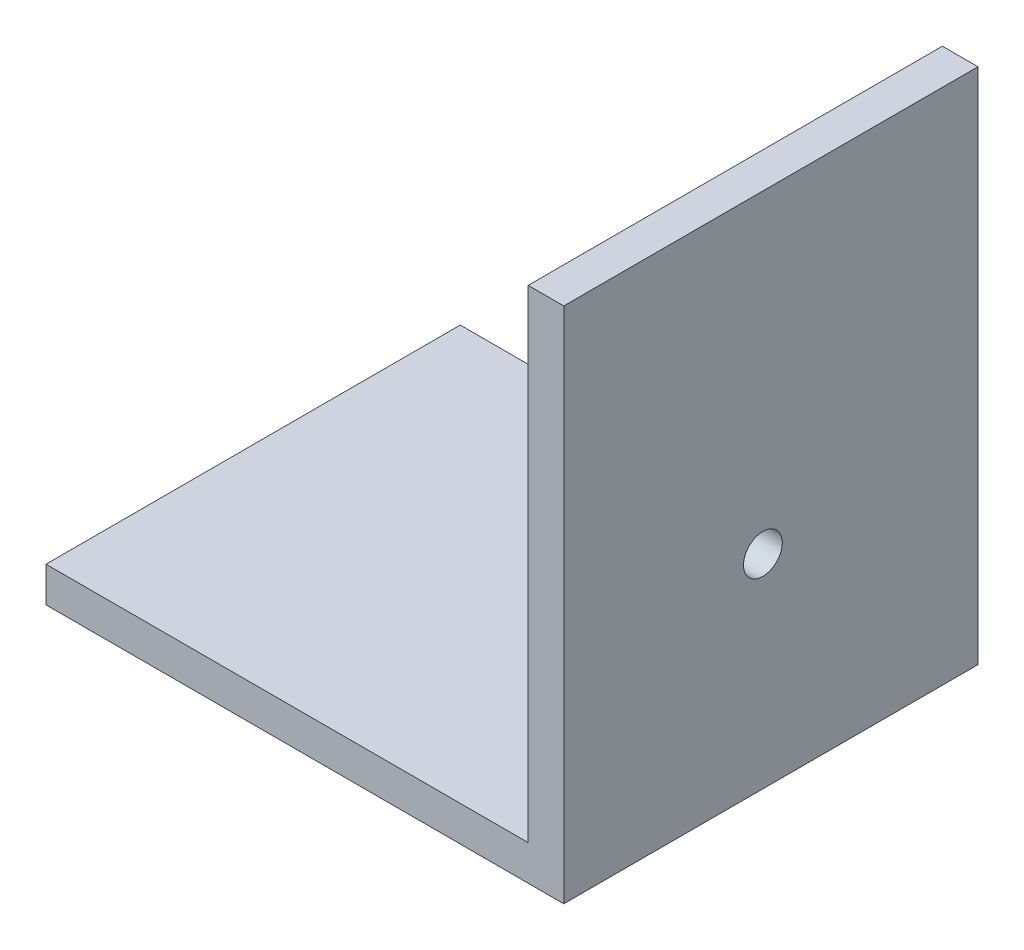
from build123d import *

# Parameters (mm, degrees)
SKETCH1_W                  = 127
SKETCH1_H                  = 8.636
BOSS_EXTRUDE1_DEPTH        = 101.6
SKETCH3_W                  = 8.7376
SKETCH3_H                  = 118.364
BOSS_EXTRUDE2_DEPTH        = 101.6
F_1_2_0_5000_DOWEL_HOLE2_D = 12.7
F_3_8_0_3750_DOWEL_HOLE3_D = 9.525


with BuildPart() as part:
    # Sketch1 → Boss-Extrude1 (new body)
    with BuildSketch(Plane.XY):
        Rectangle(SKETCH1_W, SKETCH1_H)
    extrude(amount=BOSS_EXTRUDE1_DEPTH)

    # Sketch3 → Boss-Extrude2 (add, through all)
    with BuildSketch(Plane.XY.offset(101.6)):
        with Locations((59.1312, 63.5)):
            Rectangle(SKETCH3_W, SKETCH3_H)
    extrude(amount=-BOSS_EXTRUDE2_DEPTH)

    # 1/2 (0.5000) Dowel Hole2 (through all)
    with Locations(Plane(origin=(16.6624, 4.318, 50.8), x_dir=(0, 0, 1), z_dir=(0, 1, 0))):
        with Locations((0, 0)):
            Hole(F_1_2_0_5000_DOWEL_HOLE2_D / 2)

    # 3/8 (0.3750) Dowel Hole3 (through all)
    with Locations(Plane(origin=(54.7624, 45.593, 52.765386082), x_dir=(0, 0, -1), z_dir=(-1, 0, 0))):
        with Locations((0, 0)):
            Hole(F_3_8_0_3750_DOWEL_HOLE3_D / 2)


solid = part.part
